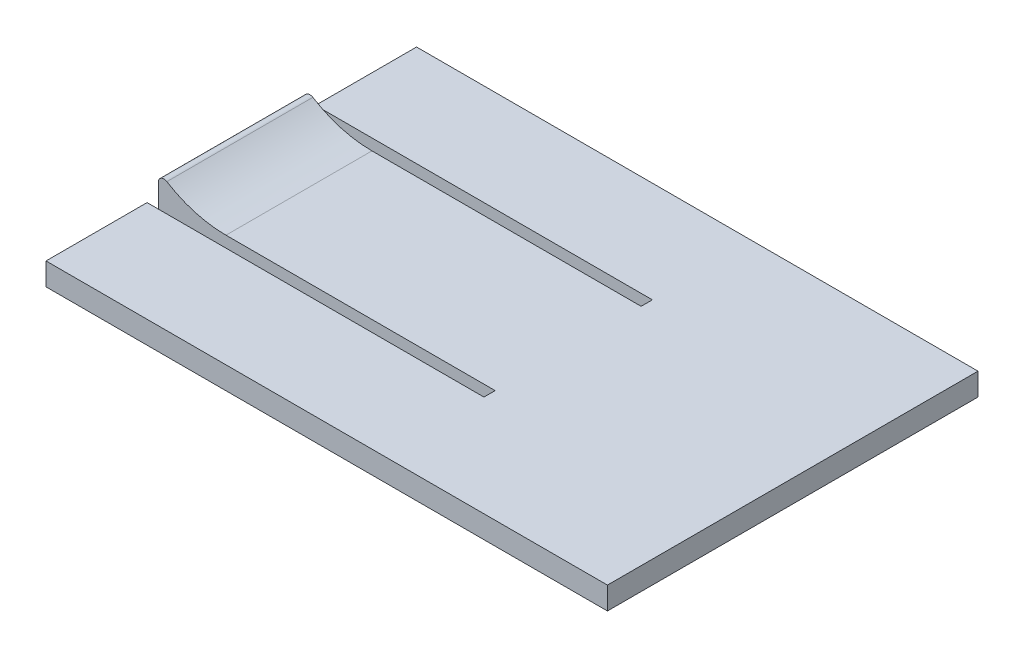
from build123d import *

# Parameters (mm, degrees)
SKETCH2_W           = 33
SKETCH2_H           = 2
BOSS_EXTRUDE1_DEPTH = 50
SKETCH3_W           = 30
SKETCH3_H           = 1
CUT_EXTRUDE2_DEPTH  = 50
SKETCH4_W           = 3
SKETCH4_H           = 13
BOSS_EXTRUDE2_DEPTH = 2
CUT_EXTRUDE3_DEPTH  = 13
FILLET1_R           = 10
FILLET2_R           = 0.5


with BuildPart() as part:
    # Sketch2 → Boss-Extrude1 (new body)
    with BuildSketch(Plane(origin=(0, 0, 0), x_dir=(0, 0, -1), z_dir=(1, 0, 0))):
        with Locations((-16.5, 1)):
            Rectangle(SKETCH2_W, SKETCH2_H)
    extrude(amount=BOSS_EXTRUDE1_DEPTH)

    # Sketch3 → Cut-Extrude2 (cut)
    with BuildSketch(Plane(origin=(0, 2, 0), x_dir=(1, 0, 0), z_dir=(0, 1, 0))):
        with Locations((15, -9.5)):
            Rectangle(SKETCH3_W, SKETCH3_H)
        with Locations((15, -23.5)):
            Rectangle(SKETCH3_W, SKETCH3_H)
    extrude(amount=-CUT_EXTRUDE2_DEPTH, mode=Mode.SUBTRACT)

    # Sketch4 → Boss-Extrude2 (add)
    with BuildSketch(Plane(origin=(0, 2, 0), x_dir=(1, 0, 0), z_dir=(0, 1, 0))):
        with Locations((1.5, -16.5)):
            Rectangle(SKETCH4_W, SKETCH4_H)
    extrude(amount=BOSS_EXTRUDE2_DEPTH)

    # Sketch5 → Cut-Extrude3 (cut)
    with BuildSketch(Plane.XY.offset(23)):
        Polygon((3, 2), (0, 4), (3, 4), align=None)
    extrude(amount=-CUT_EXTRUDE3_DEPTH, mode=Mode.SUBTRACT)

    # Fillet1
    fillet1_edges = [part.edges().sort_by_distance(p)[0] for p in [
        (3, 2, 16.5),
    ]]
    fillet(fillet1_edges, radius=FILLET1_R)

    # Fillet2
    fillet2_edges = [part.edges().sort_by_distance(p)[0] for p in [
        (0, 4, 16.5),
    ]]
    fillet(fillet2_edges, radius=FILLET2_R)


solid = part.part
